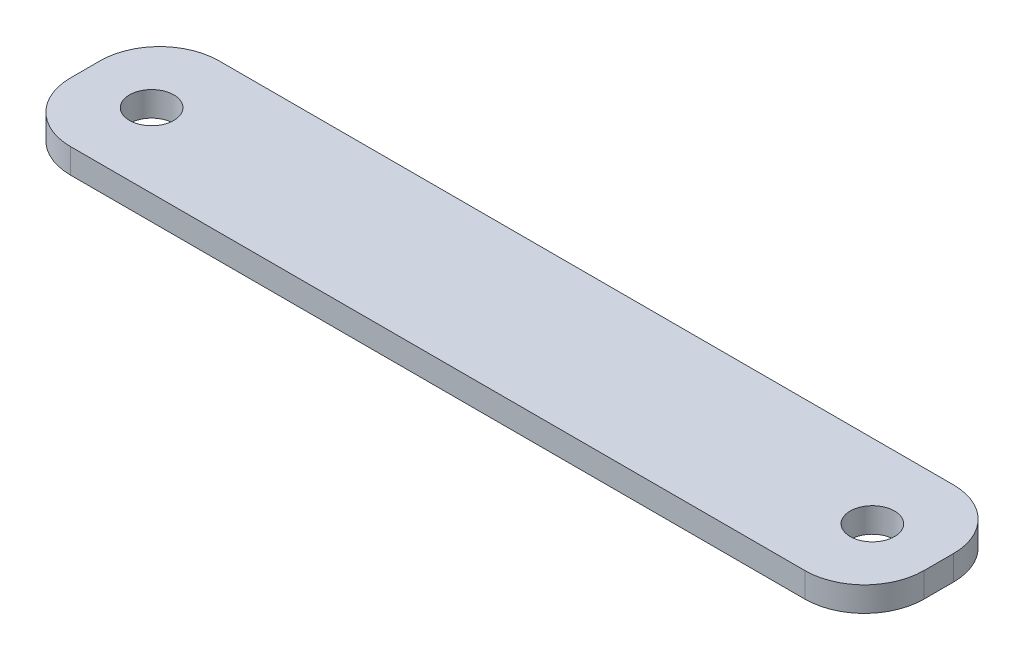
from build123d import *

# Parameters (mm, degrees)
SKETCH1_W           = 54.737
SKETCH1_H           = 9.525
BOSS_EXTRUDE1_DEPTH = 1.5875
FILLET1_R           = 3.81
SKETCH2_R           = 1.4224
CUT_EXTRUDE1_DEPTH  = 2.5875


with BuildPart() as part:
    # Sketch1 → Boss-Extrude1 (new body)
    with BuildSketch(Plane(origin=(0, 0, 0), x_dir=(1, 0, 0), z_dir=(0, 1, 0))):
        with Locations((27.3685, 4.7625)):
            Rectangle(SKETCH1_W, SKETCH1_H)
    extrude(amount=BOSS_EXTRUDE1_DEPTH)

    # Fillet1
    fillet1_edges = [part.edges().sort_by_distance(p)[0] for p in [
        (0, 0.79375, -9.525),
        (54.737, 0.79375, -9.525),
        (54.737, 0.79375, 0),
        (0, 0.79375, 0),
    ]]
    fillet(fillet1_edges, radius=FILLET1_R)

    # Sketch2 → Cut-Extrude1 (cut, through all)
    with BuildSketch(Plane(origin=(0, 1.5875, 0), x_dir=(1, 0, 0), z_dir=(0, 1, 0))):
        with Locations((4.2545, 4.7625)):
            Circle(SKETCH2_R)
        with Locations((50.4825, 4.7625)):
            Circle(SKETCH2_R)
    extrude(amount=-CUT_EXTRUDE1_DEPTH, mode=Mode.SUBTRACT)


solid = part.part
